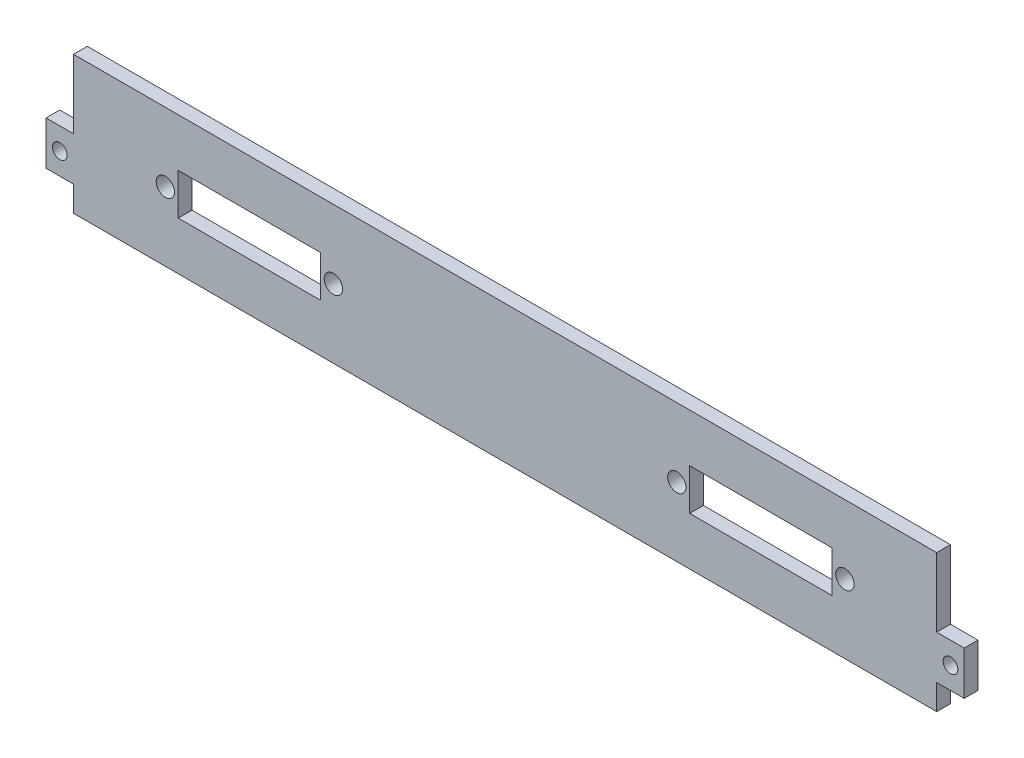
from build123d import *

# Parameters (mm, degrees)
ESBO_O1_R                = 1.6
ESBO_O1_R_2              = 2
ESBO_O1_W                = 31
ESBO_O1_H                = 9
RESSALTO_EXTRUS_O1_DEPTH = 3


with BuildPart() as part:
    # Esboço1 → Ressalto-extrusão1 (new body)
    with BuildSketch(Plane.XY):
        Polygon((-94, -9.5), (-94, -15), (94, -15), (94, -9.5), (100, -9.5), (100, 0), (94, 0), (94, 15), (-94, 15), (-94, 0), (-100, 0), (-100, -9.5), align=None)
        with Locations((-97, -4.75)):
            Circle(ESBO_O1_R, mode=Mode.SUBTRACT)
        with Locations((97, -4.75)):
            Circle(ESBO_O1_R, mode=Mode.SUBTRACT)
        with Locations((-74, 0)):
            Circle(ESBO_O1_R_2, mode=Mode.SUBTRACT)
        with Locations((-37.4, 0)):
            Circle(ESBO_O1_R_2, mode=Mode.SUBTRACT)
        with Locations((37.4, 0)):
            Circle(ESBO_O1_R_2, mode=Mode.SUBTRACT)
        with Locations((74, 0)):
            Circle(ESBO_O1_R_2, mode=Mode.SUBTRACT)
        with Locations((-55.7, 0)):
            Rectangle(ESBO_O1_W, ESBO_O1_H, mode=Mode.SUBTRACT)
        with Locations((55.7, 0)):
            Rectangle(ESBO_O1_W, ESBO_O1_H, mode=Mode.SUBTRACT)
    extrude(amount=RESSALTO_EXTRUS_O1_DEPTH)


solid = part.part
